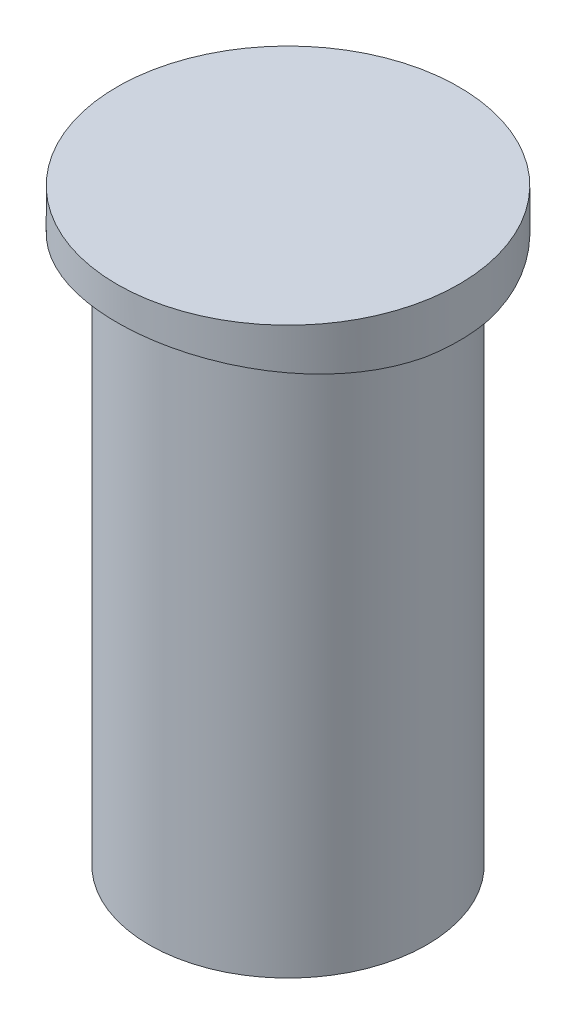
from build123d import *

# Parameters (mm, degrees)
SKETCH1_R               = 6.1849
BOSS_EXTRUDE1_DEPTH     = 23.9776
SKETCH2_R               = 7.62
BOSS_EXTRUDE2_DEPTH     = 2.2352
SKETCH4_R               = 7.62
SKETCH4_R_2             = 6.1849
CUT_EXTRUDE2_DEPTH      = 24.9776
CUT_EXTRUDE2_DEPTH_BACK = 0.0254
CUT_EXTRUDE3_DEPTH      = 8.62
CUT_EXTRUDE3_DEPTH_BACK = 8.62
SKETCH9_R               = 7.62
SKETCH9_R_2             = 6.1849
CUT_EXTRUDE4_DEPTH      = 25.003
CUT_EXTRUDE4_DEPTH_BACK = 0.0254


with BuildPart() as part:
    # Sketch1 → Boss-Extrude1 (new body)
    with BuildSketch(Plane(origin=(0, 0, 0), x_dir=(1, 0, 0), z_dir=(0, 1, 0))):
        Circle(SKETCH1_R)
    extrude(amount=BOSS_EXTRUDE1_DEPTH)

    # Sketch2 → Boss-Extrude2 (add)
    with BuildSketch(Plane(origin=(0, 23.9776, 0), x_dir=(1, 0, 0), z_dir=(0, 1, 0))):
        Circle(SKETCH2_R)
    extrude(amount=BOSS_EXTRUDE2_DEPTH)

    # Sketch4 → Cut-Extrude2 (cut, two sides)
    with BuildSketch(Plane.XZ.offset(-23.9776)) as cut_extrude2_sk:
        Circle(SKETCH4_R)
        Circle(SKETCH4_R_2, mode=Mode.SUBTRACT)
    extrude(amount=CUT_EXTRUDE2_DEPTH, mode=Mode.SUBTRACT)
    extrude(cut_extrude2_sk.sketch, amount=-CUT_EXTRUDE2_DEPTH_BACK, mode=Mode.SUBTRACT)

    # Sketch8 → Cut-Extrude3 (cut, two sides)
    with BuildSketch(Plane.XY) as cut_extrude3_sk:
        with BuildLine():
            Line((-7.601459966, 24.008409454), (7.601459966, 24.008409454))
            ThreePointArc((7.601459966, 24.008409454), (0, 24.7396), (-7.601459966, 24.008409454))
        make_face()
    extrude(amount=CUT_EXTRUDE3_DEPTH, mode=Mode.SUBTRACT)
    extrude(cut_extrude3_sk.sketch, amount=-CUT_EXTRUDE3_DEPTH_BACK, mode=Mode.SUBTRACT)

    # Sketch9 → Cut-Extrude4 (cut, two sides)
    with BuildSketch(Plane.XZ.offset(-24.003)) as cut_extrude4_sk:
        Circle(SKETCH9_R)
        Circle(SKETCH9_R_2, mode=Mode.SUBTRACT)
    extrude(amount=CUT_EXTRUDE4_DEPTH, mode=Mode.SUBTRACT)
    extrude(cut_extrude4_sk.sketch, amount=-CUT_EXTRUDE4_DEPTH_BACK, mode=Mode.SUBTRACT)


solid = part.part
